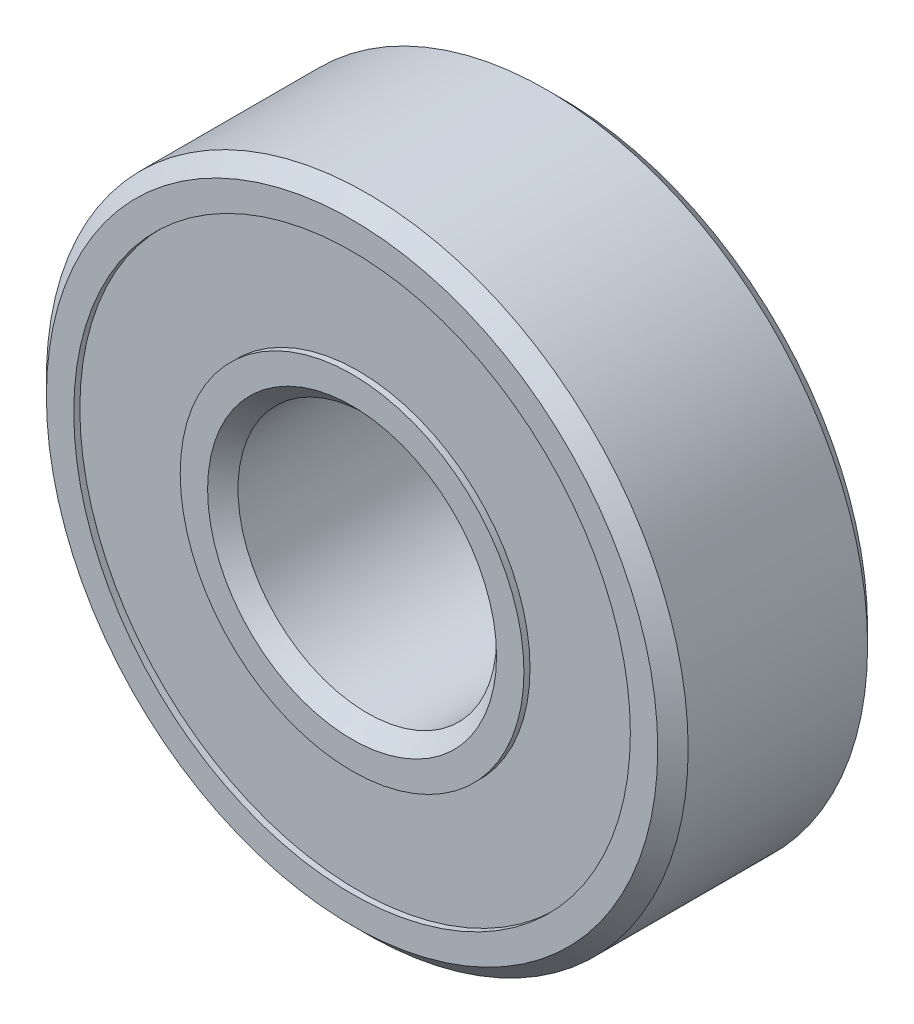
from build123d import *

# Parameters (mm, degrees)
ESQUISSE1_R        = 10.55
ESQUISSE1_R_2      = 9.15
BOSS_EXTRU_1_DEPTH = 3.45
ESQUISSE1_3_R      = 5.65
ESQUISSE1_3_R_2    = 4.25
BOSS_EXTRU_2_DEPTH = 3.45
ESQUISSE1_4_R      = 9.15
ESQUISSE1_4_R_2    = 5.65
BOSS_EXTRU_3_DEPTH = 3.25
CHANFREIN1_SIZE    = 0.5


with BuildPart() as part:
    # Esquisse1 → Boss.-Extru.1 (new, symmetric)
    with BuildSketch(Plane.XY):
        Circle(ESQUISSE1_R)
        Circle(ESQUISSE1_R_2, mode=Mode.SUBTRACT)
    extrude(amount=BOSS_EXTRU_1_DEPTH, both=True)



with BuildPart() as body_2:
    # Esquisse1_3 → Boss.-Extru.2 (new, symmetric)
    with BuildSketch(Plane.XY):
        Circle(ESQUISSE1_3_R)
        Circle(ESQUISSE1_3_R_2, mode=Mode.SUBTRACT)
    extrude(amount=BOSS_EXTRU_2_DEPTH, both=True)


with BuildPart() as part_1:
    add(part.part)

    add(body_2.part)  # Boss.-Extru.3 merges body 2
    # Esquisse1_4 → Boss.-Extru.3 (add, symmetric)
    with BuildSketch(Plane.XY):
        Circle(ESQUISSE1_4_R)
        Circle(ESQUISSE1_4_R_2, mode=Mode.SUBTRACT)
    extrude(amount=BOSS_EXTRU_3_DEPTH, both=True)

    # Chanfrein1
    chanfrein1_edges = [part_1.edges().sort_by_distance(p)[0] for p in [
        (-4.25, 0, -3.45),
        (-10.55, 0, -3.45),
        (-10.55, 0, 3.45),
        (-4.25, 0, 3.45),
    ]]
    chamfer(chanfrein1_edges, length=CHANFREIN1_SIZE)


solid = part_1.part
